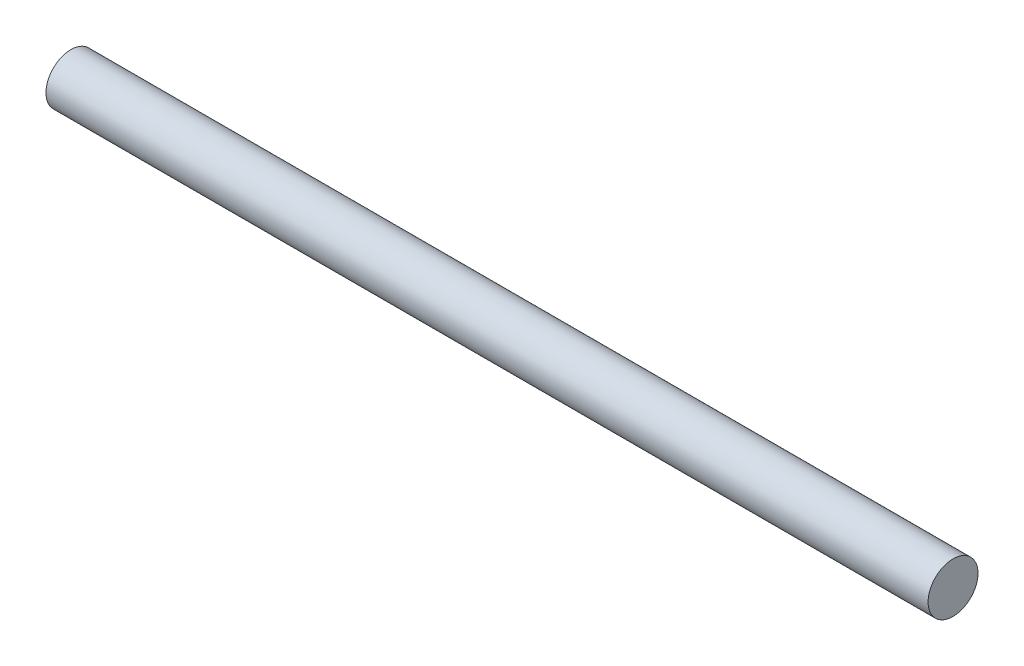
from build123d import *

# Parameters (mm, degrees)
IZIM1_R                     = 6
Y_KSEKLIK_EKSTR_ZYON1_DEPTH = 212


with BuildPart() as part:
    # Çizim1 → Yükseklik-Ekstrüzyon1 (new body)
    with BuildSketch(Plane(origin=(0, 0, 0), x_dir=(0, 0, -1), z_dir=(1, 0, 0))):
        Circle(IZIM1_R)
    extrude(amount=Y_KSEKLIK_EKSTR_ZYON1_DEPTH)


solid = part.part
